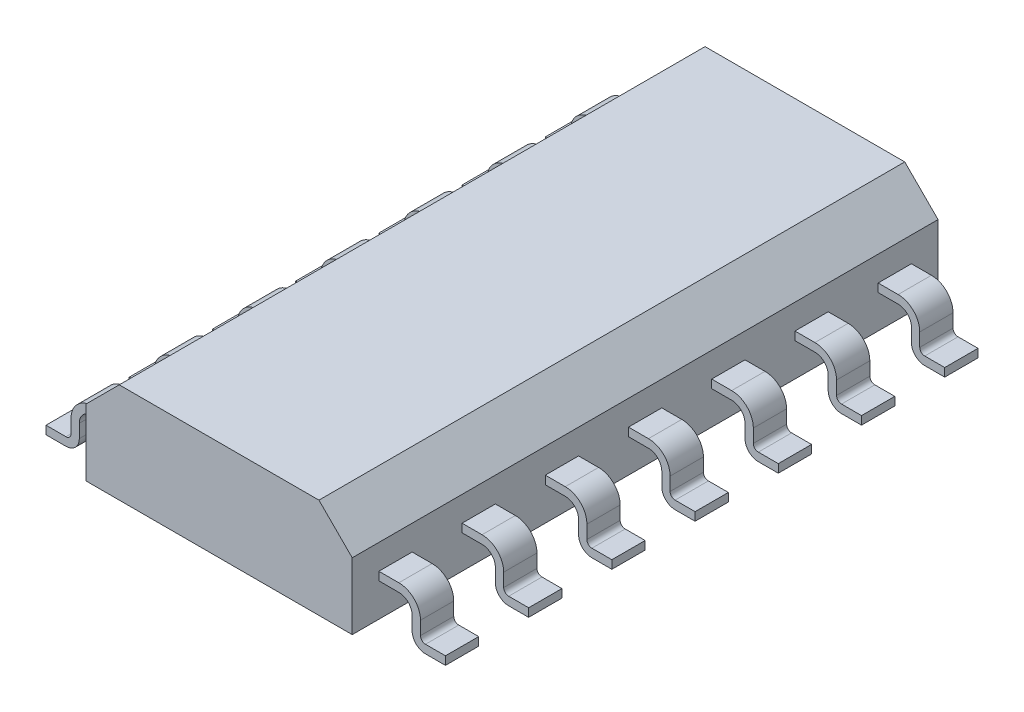
from build123d import *

# Parameters (mm, degrees)
EXTRUDE1_DEPTH       = 4.4
EXTRUDE2_DEPTH       = 0.5
LPATTERN1_COUNT      = 7
LPATTERN1_PITCH      = 1.25
MIRROR1_COPY_1_DEPTH = 0.5
MIRROR1_COPY_2_DEPTH = 0.5
MIRROR1_COPY_3_DEPTH = 0.5
MIRROR1_COPY_4_DEPTH = 0.5
MIRROR1_COPY_5_DEPTH = 0.5
MIRROR1_COPY_6_DEPTH = 0.5


with BuildPart() as part:
    # Sketch1 → Extrude1 (new body, symmetric)
    with BuildSketch(Plane.XY):
        Polygon((-2, -0.75), (2, -0.75), (2, 0.25), (1.5, 0.75), (-1.5, 0.75), (-2, 0.25), align=None)
    extrude(amount=EXTRUDE1_DEPTH, both=True)

    # Sketch2 → Extrude2 (add)
    with BuildSketch(Plane.XY.offset(4)):
        with BuildLine():
            Line((-2.5, -0.65), (-2.5, -0.45))
            ThreePointArc((-2.5, -0.45), (-2.441421356, -0.308578644), (-2.3, -0.25))
            Line((-2.3, -0.25), (-2, -0.25))
            Line((-2, -0.25), (-2, -0.125))
            Line((-2, -0.125), (-2.3, -0.125))
            ThreePointArc((-2.3, -0.125), (-2.529809704, -0.220190296), (-2.625, -0.45))
            Line((-2.625, -0.45), (-2.625, -0.65))
            ThreePointArc((-2.625, -0.65), (-2.646966991, -0.703033009), (-2.7, -0.725))
            Line((-2.7, -0.725), (-3, -0.725))
            Line((-3, -0.725), (-3, -0.85))
            Line((-3, -0.85), (-2.7, -0.85))
            ThreePointArc((-2.7, -0.85), (-2.558578644, -0.791421356), (-2.5, -0.65))
        make_face()
    extrude2 = extrude(amount=-EXTRUDE2_DEPTH)

    # LPattern1: Extrude2 ×7
    with Locations(*[(0, 0, -i * LPATTERN1_PITCH) for i in range(1, LPATTERN1_COUNT)]):
        add(extrude2)

    # Mirror1: Extrude2 across plane
    add(extrude2.mirror(Plane(origin=(0, 0, 0), x_dir=(0, 0, 1), z_dir=(1, 0, 0))))

    # Mirror1 copy 1 sketch → Mirror1 copy 1 (add)
    with BuildSketch(Plane(origin=(0, 0, 2.75), x_dir=(-1, 0, 0), z_dir=(0, 0, 1))):
        with BuildLine():
            Line((-2.5, 0.65), (-2.5, 0.45))
            ThreePointArc((-2.5, 0.45), (-2.441421356, 0.308578644), (-2.3, 0.25))
            Line((-2.3, 0.25), (-2, 0.25))
            Line((-2, 0.25), (-2, 0.125))
            Line((-2, 0.125), (-2.3, 0.125))
            ThreePointArc((-2.3, 0.125), (-2.529809704, 0.220190296), (-2.625, 0.45))
            Line((-2.625, 0.45), (-2.625, 0.65))
            ThreePointArc((-2.625, 0.65), (-2.646966991, 0.703033009), (-2.7, 0.725))
            Line((-2.7, 0.725), (-3, 0.725))
            Line((-3, 0.725), (-3, 0.85))
            Line((-3, 0.85), (-2.7, 0.85))
            ThreePointArc((-2.7, 0.85), (-2.558578644, 0.791421356), (-2.5, 0.65))
        make_face()
    extrude(amount=-MIRROR1_COPY_1_DEPTH)

    # Mirror1 copy 2 sketch → Mirror1 copy 2 (add)
    with BuildSketch(Plane(origin=(0, 0, 1.5), x_dir=(-1, 0, 0), z_dir=(0, 0, 1))):
        with BuildLine():
            Line((-2.5, 0.65), (-2.5, 0.45))
            ThreePointArc((-2.5, 0.45), (-2.441421356, 0.308578644), (-2.3, 0.25))
            Line((-2.3, 0.25), (-2, 0.25))
            Line((-2, 0.25), (-2, 0.125))
            Line((-2, 0.125), (-2.3, 0.125))
            ThreePointArc((-2.3, 0.125), (-2.529809704, 0.220190296), (-2.625, 0.45))
            Line((-2.625, 0.45), (-2.625, 0.65))
            ThreePointArc((-2.625, 0.65), (-2.646966991, 0.703033009), (-2.7, 0.725))
            Line((-2.7, 0.725), (-3, 0.725))
            Line((-3, 0.725), (-3, 0.85))
            Line((-3, 0.85), (-2.7, 0.85))
            ThreePointArc((-2.7, 0.85), (-2.558578644, 0.791421356), (-2.5, 0.65))
        make_face()
    extrude(amount=-MIRROR1_COPY_2_DEPTH)

    # Mirror1 copy 3 sketch → Mirror1 copy 3 (add)
    with BuildSketch(Plane(origin=(0, 0, 0.25), x_dir=(-1, 0, 0), z_dir=(0, 0, 1))):
        with BuildLine():
            Line((-2.5, 0.65), (-2.5, 0.45))
            ThreePointArc((-2.5, 0.45), (-2.441421356, 0.308578644), (-2.3, 0.25))
            Line((-2.3, 0.25), (-2, 0.25))
            Line((-2, 0.25), (-2, 0.125))
            Line((-2, 0.125), (-2.3, 0.125))
            ThreePointArc((-2.3, 0.125), (-2.529809704, 0.220190296), (-2.625, 0.45))
            Line((-2.625, 0.45), (-2.625, 0.65))
            ThreePointArc((-2.625, 0.65), (-2.646966991, 0.703033009), (-2.7, 0.725))
            Line((-2.7, 0.725), (-3, 0.725))
            Line((-3, 0.725), (-3, 0.85))
            Line((-3, 0.85), (-2.7, 0.85))
            ThreePointArc((-2.7, 0.85), (-2.558578644, 0.791421356), (-2.5, 0.65))
        make_face()
    extrude(amount=-MIRROR1_COPY_3_DEPTH)

    # Mirror1 copy 4 sketch → Mirror1 copy 4 (add)
    with BuildSketch(Plane(origin=(0, 0, -1), x_dir=(-1, 0, 0), z_dir=(0, 0, 1))):
        with BuildLine():
            Line((-2.5, 0.65), (-2.5, 0.45))
            ThreePointArc((-2.5, 0.45), (-2.441421356, 0.308578644), (-2.3, 0.25))
            Line((-2.3, 0.25), (-2, 0.25))
            Line((-2, 0.25), (-2, 0.125))
            Line((-2, 0.125), (-2.3, 0.125))
            ThreePointArc((-2.3, 0.125), (-2.529809704, 0.220190296), (-2.625, 0.45))
            Line((-2.625, 0.45), (-2.625, 0.65))
            ThreePointArc((-2.625, 0.65), (-2.646966991, 0.703033009), (-2.7, 0.725))
            Line((-2.7, 0.725), (-3, 0.725))
            Line((-3, 0.725), (-3, 0.85))
            Line((-3, 0.85), (-2.7, 0.85))
            ThreePointArc((-2.7, 0.85), (-2.558578644, 0.791421356), (-2.5, 0.65))
        make_face()
    extrude(amount=-MIRROR1_COPY_4_DEPTH)

    # Mirror1 copy 5 sketch → Mirror1 copy 5 (add)
    with BuildSketch(Plane(origin=(0, 0, -2.25), x_dir=(-1, 0, 0), z_dir=(0, 0, 1))):
        with BuildLine():
            Line((-2.5, 0.65), (-2.5, 0.45))
            ThreePointArc((-2.5, 0.45), (-2.441421356, 0.308578644), (-2.3, 0.25))
            Line((-2.3, 0.25), (-2, 0.25))
            Line((-2, 0.25), (-2, 0.125))
            Line((-2, 0.125), (-2.3, 0.125))
            ThreePointArc((-2.3, 0.125), (-2.529809704, 0.220190296), (-2.625, 0.45))
            Line((-2.625, 0.45), (-2.625, 0.65))
            ThreePointArc((-2.625, 0.65), (-2.646966991, 0.703033009), (-2.7, 0.725))
            Line((-2.7, 0.725), (-3, 0.725))
            Line((-3, 0.725), (-3, 0.85))
            Line((-3, 0.85), (-2.7, 0.85))
            ThreePointArc((-2.7, 0.85), (-2.558578644, 0.791421356), (-2.5, 0.65))
        make_face()
    extrude(amount=-MIRROR1_COPY_5_DEPTH)

    # Mirror1 copy 6 sketch → Mirror1 copy 6 (add)
    with BuildSketch(Plane(origin=(0, 0, -3.5), x_dir=(-1, 0, 0), z_dir=(0, 0, 1))):
        with BuildLine():
            Line((-2.5, 0.65), (-2.5, 0.45))
            ThreePointArc((-2.5, 0.45), (-2.441421356, 0.308578644), (-2.3, 0.25))
            Line((-2.3, 0.25), (-2, 0.25))
            Line((-2, 0.25), (-2, 0.125))
            Line((-2, 0.125), (-2.3, 0.125))
            ThreePointArc((-2.3, 0.125), (-2.529809704, 0.220190296), (-2.625, 0.45))
            Line((-2.625, 0.45), (-2.625, 0.65))
            ThreePointArc((-2.625, 0.65), (-2.646966991, 0.703033009), (-2.7, 0.725))
            Line((-2.7, 0.725), (-3, 0.725))
            Line((-3, 0.725), (-3, 0.85))
            Line((-3, 0.85), (-2.7, 0.85))
            ThreePointArc((-2.7, 0.85), (-2.558578644, 0.791421356), (-2.5, 0.65))
        make_face()
    extrude(amount=-MIRROR1_COPY_6_DEPTH)


solid = part.part
